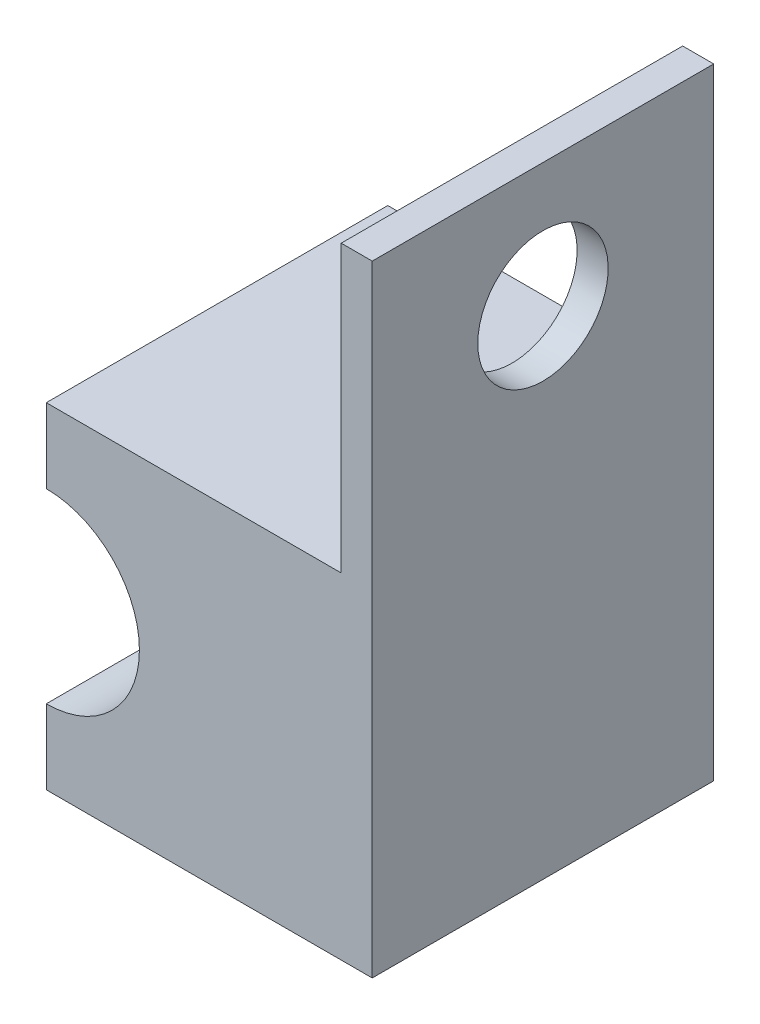
from build123d import *

# Parameters (mm, degrees)
BOSS_EXTRUDE1_DEPTH = 11
SKETCH2_W           = 1
SKETCH2_H           = 11
BOSS_EXTRUDE2_DEPTH = 9.2
SKETCH3_R           = 2.1
CUT_EXTRUDE1_DEPTH  = 10


with BuildPart() as part:
    # Sketch1 → Boss-Extrude1 (new body)
    with BuildSketch(Plane.XY):
        with BuildLine():
            Line((0, 0), (0, 2.4))
            ThreePointArc((0, 2.4), (3, 5.4), (0, 8.4))
            Line((0, 8.4), (0, 10.8))
            Line((0, 10.8), (10.5, 10.8))
            Line((10.5, 10.8), (10.5, 0))
            Line((10.5, 0), (0, 0))
        make_face()
    extrude(amount=BOSS_EXTRUDE1_DEPTH)

    # Sketch2 → Boss-Extrude2 (add)
    with BuildSketch(Plane(origin=(0, 10.8, 0), x_dir=(1, 0, 0), z_dir=(0, 1, 0))):
        with Locations((10, -5.5)):
            Rectangle(SKETCH2_W, SKETCH2_H)
    extrude(amount=BOSS_EXTRUDE2_DEPTH)

    # Sketch3 → Cut-Extrude1 (cut)
    with BuildSketch(Plane.ZY.offset(-9.5)):
        with Locations((5.5, 16)):
            Circle(SKETCH3_R)
    extrude(amount=-CUT_EXTRUDE1_DEPTH, mode=Mode.SUBTRACT)


solid = part.part
